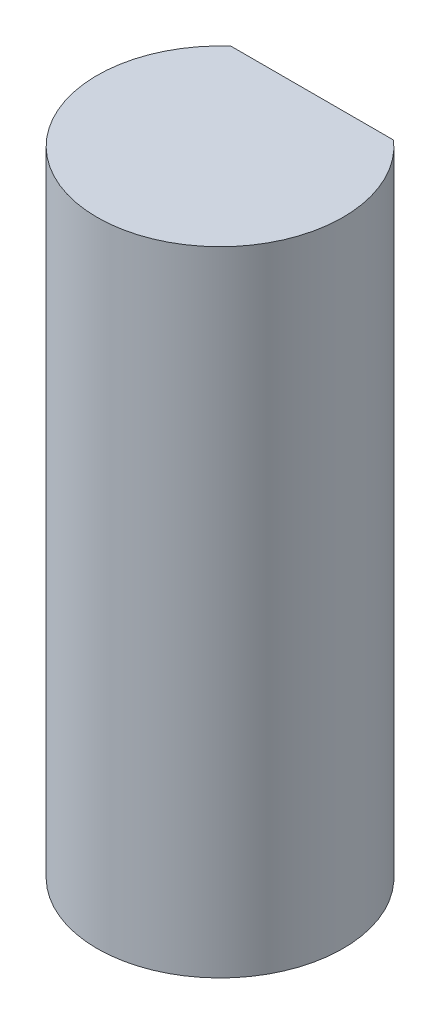
from build123d import *

# Parameters (mm, degrees)
ESQUISSE1_R             = 4
EXTRUSION1_DEPTH        = 20.6
ENL_V_MAT_EXTRU_1_DEPTH = 10


with BuildPart() as part:
    # Esquisse1 → Extrusion1 (new body)
    with BuildSketch(Plane(origin=(0, 0, 0), x_dir=(1, 0, 0), z_dir=(0, 1, 0))):
        Circle(ESQUISSE1_R)
    extrude(amount=EXTRUSION1_DEPTH)

    # Esquisse2 → Enlèv. mat.-Extru.1 (cut)
    with BuildSketch(Plane(origin=(0, 20.6, 0), x_dir=(1, 0, 0), z_dir=(0, 1, 0))):
        with BuildLine():
            Line((-2.645751311, 3), (2.645751311, 3))
            ThreePointArc((2.645751311, 3), (0, 4), (-2.645751311, 3))
        make_face()
    extrude(amount=-ENL_V_MAT_EXTRU_1_DEPTH, mode=Mode.SUBTRACT)


solid = part.part
